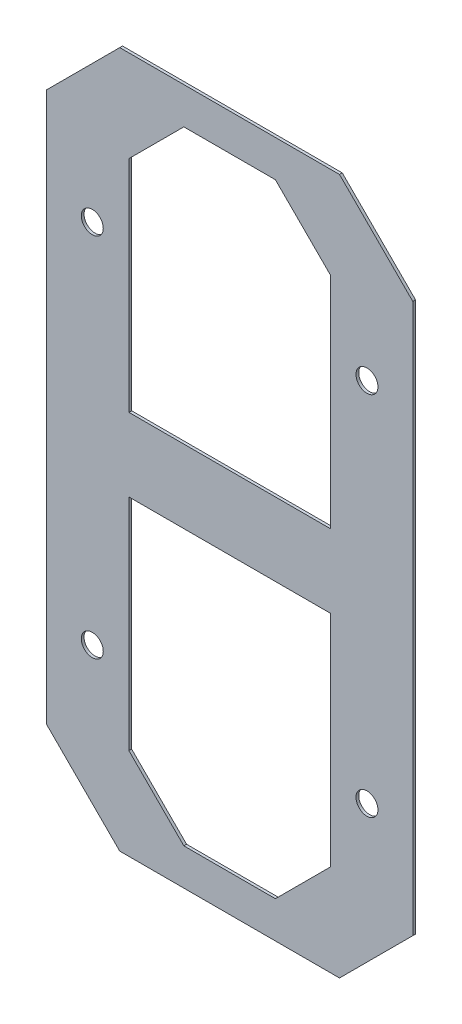
from build123d import *

# Parameters (mm, degrees)
SKETCH1_W                   = 508
SKETCH1_H                   = 965.2
BOSS_EXTRUDE1_DEPTH         = 3.81
F_1_16_1_2_DIAMETER_HOLE1_D = 30.48
CHAMFER1_SIZE               = 101.6
CUT_EXTRUDE2_DEPTH          = 4.81


with BuildPart() as part:
    # Sketch1 → Boss-Extrude1 (new body)
    with BuildSketch(Plane.XY):
        Rectangle(SKETCH1_W, SKETCH1_H)
    extrude(amount=BOSS_EXTRUDE1_DEPTH)

    # 1/16 (1.2) Diameter Hole1 (through all)
    with Locations(Plane.XY.offset(3.81)):
        with Locations((-190.5, 254), (190.5, 254), (190.5, -254), (-190.5, -254)):
            Hole(F_1_16_1_2_DIAMETER_HOLE1_D / 2)

    # Chamfer1
    chamfer1_edges = [part.edges().sort_by_distance(p)[0] for p in [
        (-254, 482.6, 1.905),
        (-254, -482.6, 1.905),
        (254, -482.6, 1.905),
        (254, 482.6, 1.905),
    ]]
    chamfer(chamfer1_edges, length=CHAMFER1_SIZE)

    # Sketch6 → Cut-Extrude2 (cut, through all)
    with BuildSketch(Plane.XY.offset(3.81)):
        Polygon((-63.5, 431.8), (63.5, 431.8), (139.7, 355.6), (139.7, 50.8), (-139.7, 50.8), (-139.7, 355.6), align=None)
        Polygon((139.7, -355.6), (139.7, -50.8), (-139.7, -50.8), (-139.7, -355.6), (-63.5, -431.8), (63.5, -431.8), align=None)
    extrude(amount=-CUT_EXTRUDE2_DEPTH, mode=Mode.SUBTRACT)


solid = part.part
